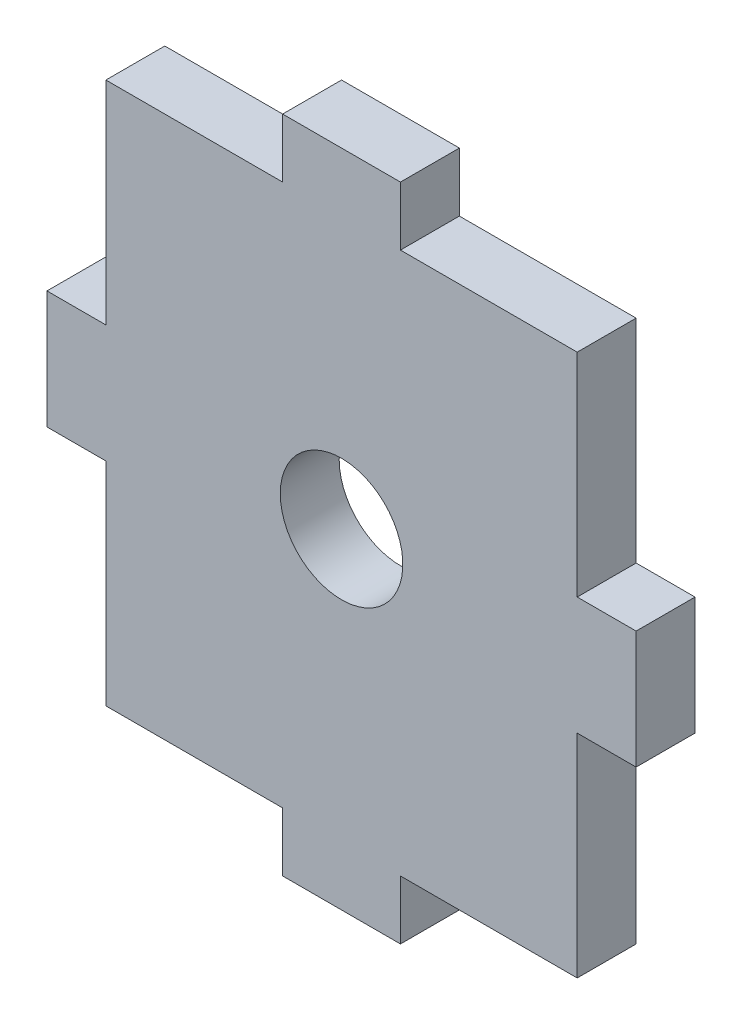
from build123d import *

# Parameters (mm, degrees)
EXTRUDE1_DEPTH     = 3.175
SKETCH2_R          = 3.302
CUT_EXTRUDE1_DEPTH = 3.175


with BuildPart() as part:
    # Sketch1 → Extrude1 (new body)
    with BuildSketch(Plane.XY):
        Polygon((-12.7, 14.605), (-3.175, 14.605), (-3.175, 17.78), (3.175, 17.78), (3.175, 14.605), (12.7, 14.605), (12.7, 3.175), (15.875, 3.175), (15.875, -3.175), (12.7, -3.175), (12.7, -14.605), (3.175, -14.605), (3.175, -17.78), (-3.175, -17.78), (-3.175, -14.605), (-12.7, -14.605), (-12.7, -3.175), (-15.875, -3.175), (-15.875, 3.175), (-12.7, 3.175), align=None)
    extrude(amount=EXTRUDE1_DEPTH)

    # Sketch2 → Cut-Extrude1 (cut)
    with BuildSketch(Plane(origin=(0, 0, 0), x_dir=(-1, 0, 0), z_dir=(0, 0, -1))):
        Circle(SKETCH2_R)
    extrude(amount=-CUT_EXTRUDE1_DEPTH, mode=Mode.SUBTRACT)


solid = part.part
